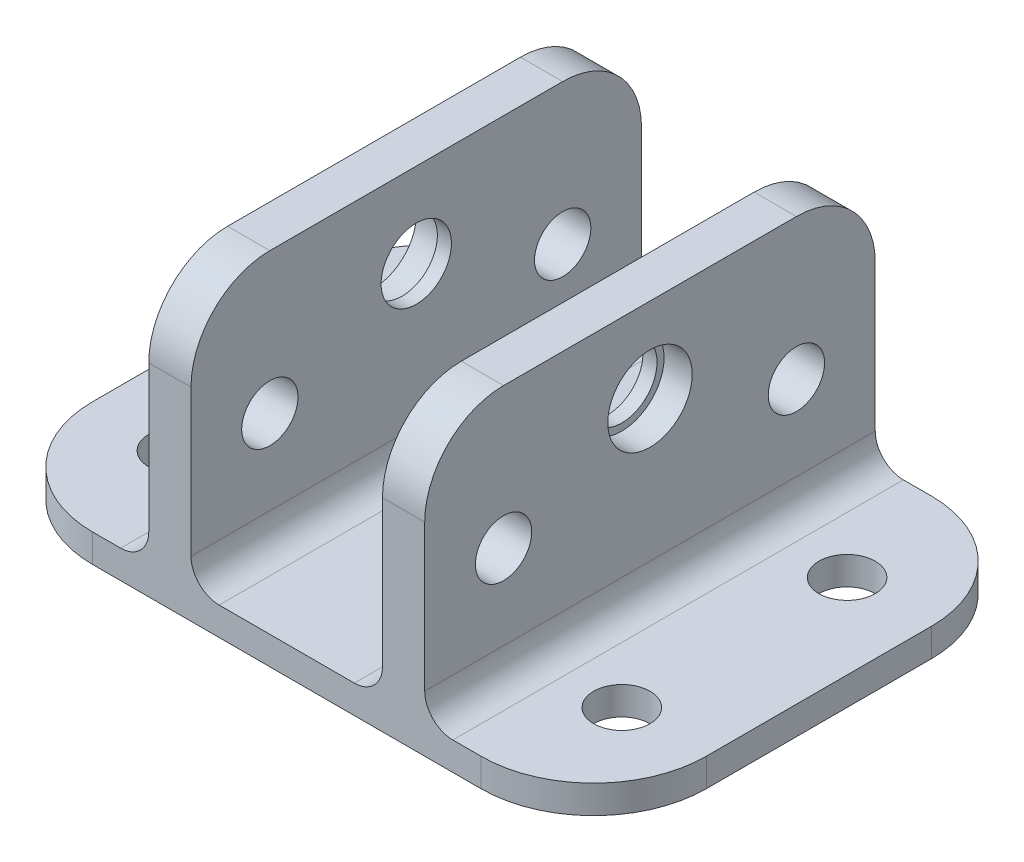
from build123d import *

# Parameters (mm, degrees)
BOSS_EXTRUDE2_DEPTH = 50.8
SKETCH4_R           = 3.175
SKETCH4_R_2         = 3.96875
CUT_EXTRUDE1_DEPTH  = 79.13596947
SKETCH5_R           = 3.175
CUT_EXTRUDE2_DEPTH  = 68.785320544
SKETCH4_3_R         = 4.7625
SKETCH4_3_R_2       = 3.96875
CUT_EXTRUDE3_DEPTH  = 3.175
CUT_EXTRUDE4_START  = -3.175
SKETCH6_R           = 4.7625
SKETCH6_R_2         = 3.96875
CUT_EXTRUDE4_DEPTH  = 3.175
FILLET1_R           = 12.7
FILLET2_R           = 3.175
FILLET3_R           = 8.89


with BuildPart() as part:
    # Sketch3 → Boss-Extrude2 (new body)
    with BuildSketch(Plane.XY):
        Polygon((-34.6075, 0), (34.6075, 0), (34.6075, 3.175), (15.5575, 3.175), (15.5575, 31.75), (10.795, 31.75), (10.795, 3.175), (-10.795, 3.175), (-10.795, 31.75), (-15.5575, 31.75), (-15.5575, 3.175), (-34.6075, 3.175), align=None)
    extrude(amount=BOSS_EXTRUDE2_DEPTH)

    # Sketch4 → Cut-Extrude1 (cut, through all)
    with BuildSketch(Plane.ZY.offset(15.5575)):
        with Locations((8.89, 15.875)):
            Circle(SKETCH4_R)
        with Locations((41.91, 15.875)):
            Circle(SKETCH4_R)
        with Locations((25.4, 22.225)):
            Circle(SKETCH4_R_2)
    extrude(amount=-CUT_EXTRUDE1_DEPTH, mode=Mode.SUBTRACT)

    # Sketch5 → Cut-Extrude2 (cut, through all)
    with BuildSketch(Plane(origin=(0, 3.175, 0), x_dir=(1, 0, 0), z_dir=(0, 1, 0))):
        with Locations((-25.0825, -12.7)):
            Circle(SKETCH5_R)
        with Locations((-25.0825, -38.1)):
            Circle(SKETCH5_R)
        with Locations((25.0825, -12.7)):
            Circle(SKETCH5_R)
        with Locations((25.0825, -38.1)):
            Circle(SKETCH5_R)
    extrude(amount=-CUT_EXTRUDE2_DEPTH, mode=Mode.SUBTRACT)

    # Sketch4_3 → Cut-Extrude3 (cut)
    with BuildSketch(Plane.ZY.offset(15.5575)):
        with Locations((25.4, 22.225)):
            Circle(SKETCH4_3_R)
        with Locations((25.4, 22.225)):
            Circle(SKETCH4_3_R_2, mode=Mode.SUBTRACT)
    extrude(amount=-CUT_EXTRUDE3_DEPTH, mode=Mode.SUBTRACT)

    # Sketch6 → Cut-Extrude4 (cut)
    with BuildSketch(Plane(origin=(15.5575, 0, 0), x_dir=(0, 0, -1), z_dir=(1, 0, 0)).offset(CUT_EXTRUDE4_START)):
        with Locations((-25.4, 22.225)):
            Circle(SKETCH6_R)
        with Locations((-25.4, 22.225)):
            Circle(SKETCH6_R_2, mode=Mode.SUBTRACT)
    extrude(amount=CUT_EXTRUDE4_DEPTH, mode=Mode.SUBTRACT)

    # Fillet1
    fillet1_edges = [part.edges().sort_by_distance(p)[0] for p in [
        (34.6075, 1.5875, 0),
        (34.6075, 1.5875, 50.8),
        (-34.6075, 1.5875, 50.8),
        (-34.6075, 1.5875, 0),
    ]]
    fillet(fillet1_edges, radius=FILLET1_R)

    # Fillet2
    fillet2_edges = [part.edges().sort_by_distance(p)[0] for p in [
        (15.5575, 3.175, 25.4),
        (10.795, 3.175, 25.4),
        (-10.795, 3.175, 25.4),
        (-15.5575, 3.175, 25.4),
    ]]
    fillet(fillet2_edges, radius=FILLET2_R)

    # Fillet3
    fillet3_edges = [part.edges().sort_by_distance(p)[0] for p in [
        (-13.17625, 31.75, 50.8),
        (13.17625, 31.75, 50.8),
        (13.17625, 31.75, 0),
        (-13.17625, 31.75, 0),
    ]]
    fillet(fillet3_edges, radius=FILLET3_R)


solid = part.part
